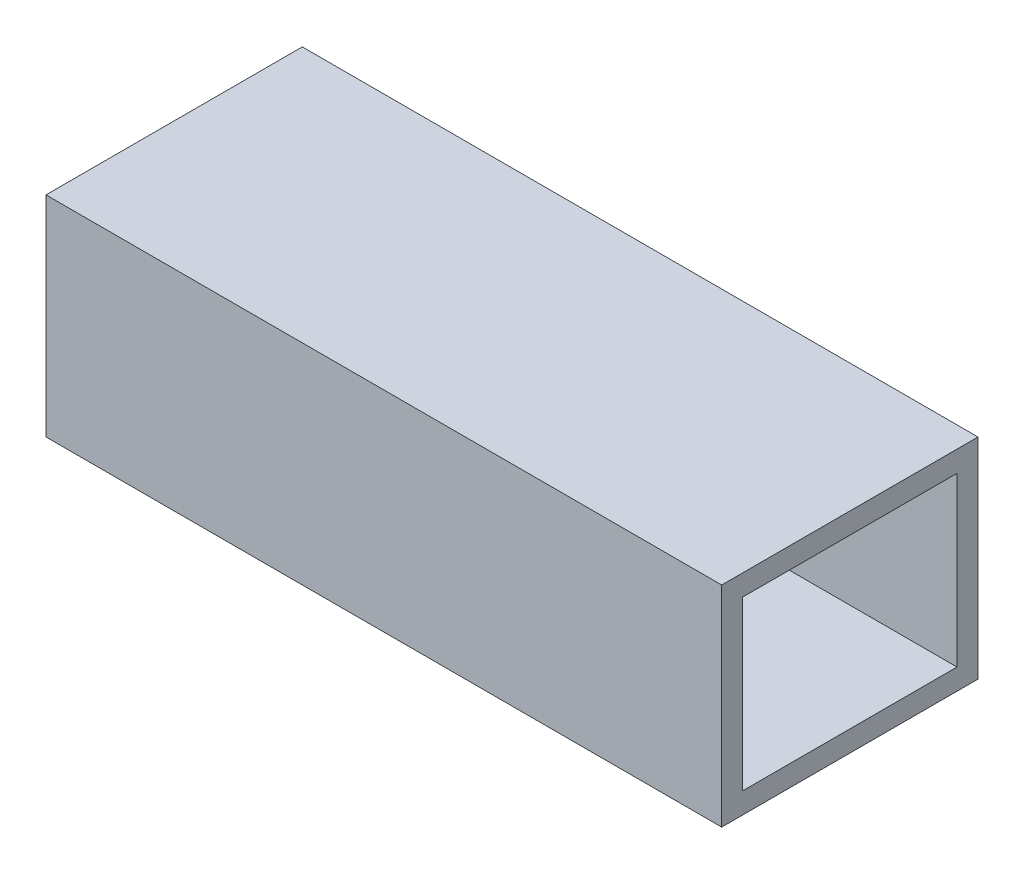
from build123d import *

# Parameters (mm, degrees)
SKETCH1_W           = 145
SKETCH1_H           = 45
BOSS_EXTRUDE1_DEPTH = 55
SKETCH2_W           = 46
SKETCH2_H           = 36
CUT_EXTRUDE1_DEPTH  = 130


with BuildPart() as part:
    # Sketch1 → Boss-Extrude1 (new body)
    with BuildSketch(Plane.XY):
        with Locations((72.5, 22.5)):
            Rectangle(SKETCH1_W, SKETCH1_H)
    extrude(amount=BOSS_EXTRUDE1_DEPTH)

    # Sketch2 → Cut-Extrude1 (cut)
    with BuildSketch(Plane(origin=(145, 0, 0), x_dir=(0, 0, -1), z_dir=(1, 0, 0))):
        with Locations((-27.5, 22.5)):
            Rectangle(SKETCH2_W, SKETCH2_H)
    extrude(amount=-CUT_EXTRUDE1_DEPTH, mode=Mode.SUBTRACT)


solid = part.part
